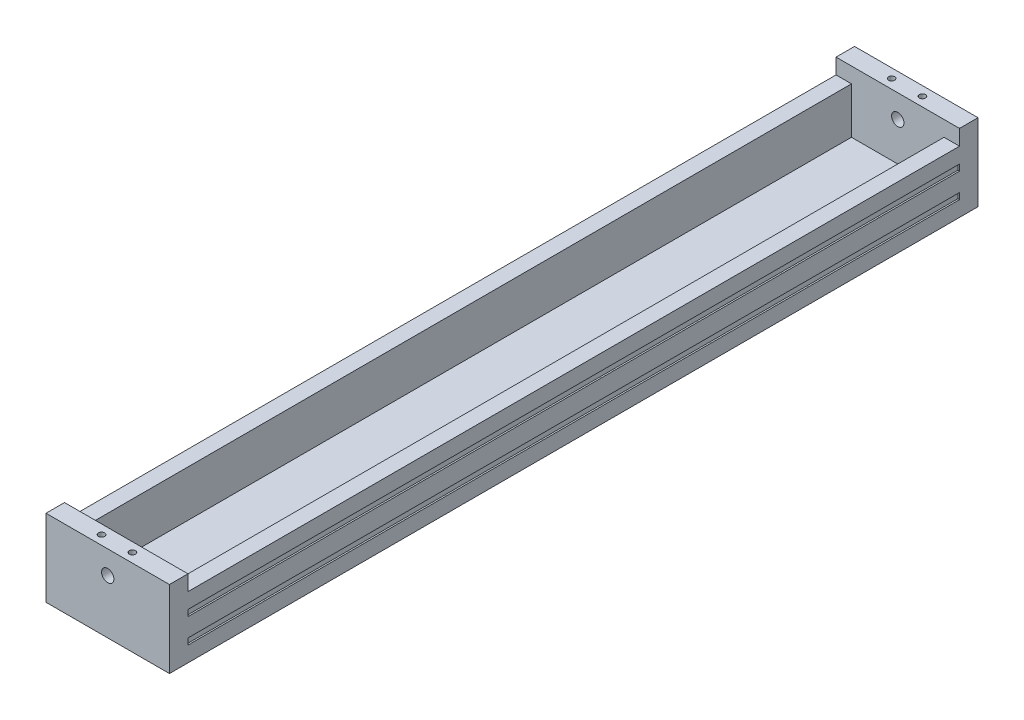
from build123d import *

# Parameters (mm, degrees)
CROQUIS1_W              = 80
CROQUIS1_H              = 50
SALIENTE_EXTRUIR1_DEPTH = 12
CROQUIS2_R              = 2
CORTAR_EXTRUIR1_DEPTH   = 3
CROQUIS3_W              = 80
CROQUIS3_H              = 40
SALIENTE_EXTRUIR2_DEPTH = 500
CROQUIS4_W              = 60
CROQUIS4_H              = 500
CORTAR_EXTRUIR2_DEPTH   = 30
CROQUIS5_W              = 500
CROQUIS5_H              = 4
CORTAR_EXTRUIR3_DEPTH   = 1
CROQUIS6_W              = 500
CROQUIS6_H              = 4
CORTAR_EXTRUIR4_DEPTH   = 1
CROQUIS7_R              = 4
CORTAR_EXTRUIR5_DEPTH   = 621


with BuildPart() as part:
    # Croquis1 → Saliente-Extruir1 (new body)
    with BuildSketch(Plane.XY):
        Rectangle(CROQUIS1_W, CROQUIS1_H)
    saliente_extruir1 = extrude(amount=SALIENTE_EXTRUIR1_DEPTH)

    # Croquis2 → Cortar-Extruir1 (cut)
    with BuildSketch(Plane(origin=(0, 25, 0), x_dir=(1, 0, 0), z_dir=(0, 1, 0))):
        with Locations((-10, -6)):
            Circle(CROQUIS2_R)
        with Locations((10, -6)):
            Circle(CROQUIS2_R)
    cortar_extruir1 = extrude(amount=-CORTAR_EXTRUIR1_DEPTH, mode=Mode.SUBTRACT)

    # Croquis3 → Saliente-Extruir2 (add)
    with BuildSketch(Plane(origin=(0, 0, 0), x_dir=(-1, 0, 0), z_dir=(0, 0, -1))):
        with Locations((0, -5)):
            Rectangle(CROQUIS3_W, CROQUIS3_H)
    extrude(amount=SALIENTE_EXTRUIR2_DEPTH)

    # Croquis4 → Cortar-Extruir2 (cut)
    with BuildSketch(Plane(origin=(0, 15, 0), x_dir=(1, 0, 0), z_dir=(0, 1, 0))):
        with Locations((0, 250)):
            Rectangle(CROQUIS4_W, CROQUIS4_H)
    extrude(amount=-CORTAR_EXTRUIR2_DEPTH, mode=Mode.SUBTRACT)

    # Croquis5 → Cortar-Extruir3 (cut)
    with BuildSketch(Plane.ZY.offset(40)):
        with Locations((-250, 3)):
            Rectangle(CROQUIS5_W, CROQUIS5_H)
        with Locations((-250, -13)):
            Rectangle(CROQUIS5_W, CROQUIS5_H)
    extrude(amount=-CORTAR_EXTRUIR3_DEPTH, mode=Mode.SUBTRACT)

    # Croquis6 → Cortar-Extruir4 (cut)
    with BuildSketch(Plane(origin=(40, 0, 0), x_dir=(0, 0, -1), z_dir=(1, 0, 0))):
        with Locations((250, 3)):
            Rectangle(CROQUIS6_W, CROQUIS6_H)
        with Locations((250, -13)):
            Rectangle(CROQUIS6_W, CROQUIS6_H)
    extrude(amount=-CORTAR_EXTRUIR4_DEPTH, mode=Mode.SUBTRACT)

    # Simetría1: Saliente-Extruir1, Cortar-Extruir1 across plane
    add(saliente_extruir1.mirror(Plane(origin=(0, 0, -250), x_dir=(1, 0, 0), z_dir=(0, 0, -1))))
    add(cortar_extruir1.mirror(Plane(origin=(0, 0, -250), x_dir=(1, 0, 0), z_dir=(0, 0, -1))), mode=Mode.SUBTRACT)

    # Croquis7 → Cortar-Extruir5 (cut)
    with BuildSketch(Plane(origin=(0, 0, -512), x_dir=(-1, 0, 0), z_dir=(0, 0, -1))):
        with Locations((0, 10)):
            Circle(CROQUIS7_R)
    extrude(amount=-CORTAR_EXTRUIR5_DEPTH, mode=Mode.SUBTRACT)


solid = part.part
